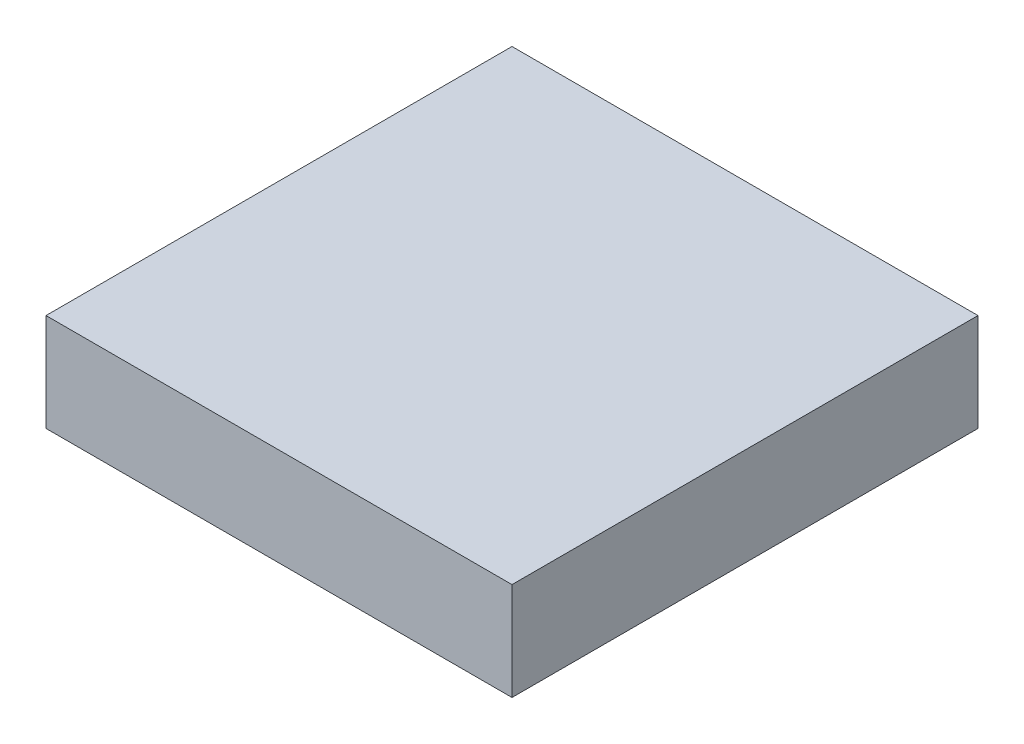
from build123d import *

# Parameters (mm, degrees)
SKETCH1_W           = 170.18
SKETCH1_H           = 170.18
BOSS_EXTRUDE1_DEPTH = 35.7124


with BuildPart() as part:
    # Sketch1 → Boss-Extrude1 (new body)
    with BuildSketch(Plane(origin=(0, 0, 0), x_dir=(1, 0, 0), z_dir=(0, 1, 0))):
        with Locations((85.09, 85.09)):
            Rectangle(SKETCH1_W, SKETCH1_H)
    extrude(amount=BOSS_EXTRUDE1_DEPTH)


solid = part.part
